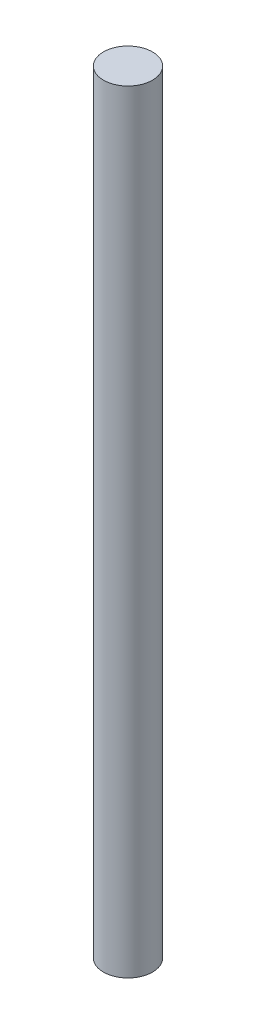
from build123d import *

# Parameters (mm, degrees)
SKETCH1_R           = 3.175
BOSS_EXTRUDE1_DEPTH = 100


with BuildPart() as part:
    # Sketch1 → Boss-Extrude1 (new body)
    with BuildSketch(Plane(origin=(0, 0, 0), x_dir=(1, 0, 0), z_dir=(0, 1, 0))):
        Circle(SKETCH1_R)
    extrude(amount=BOSS_EXTRUDE1_DEPTH)


solid = part.part
